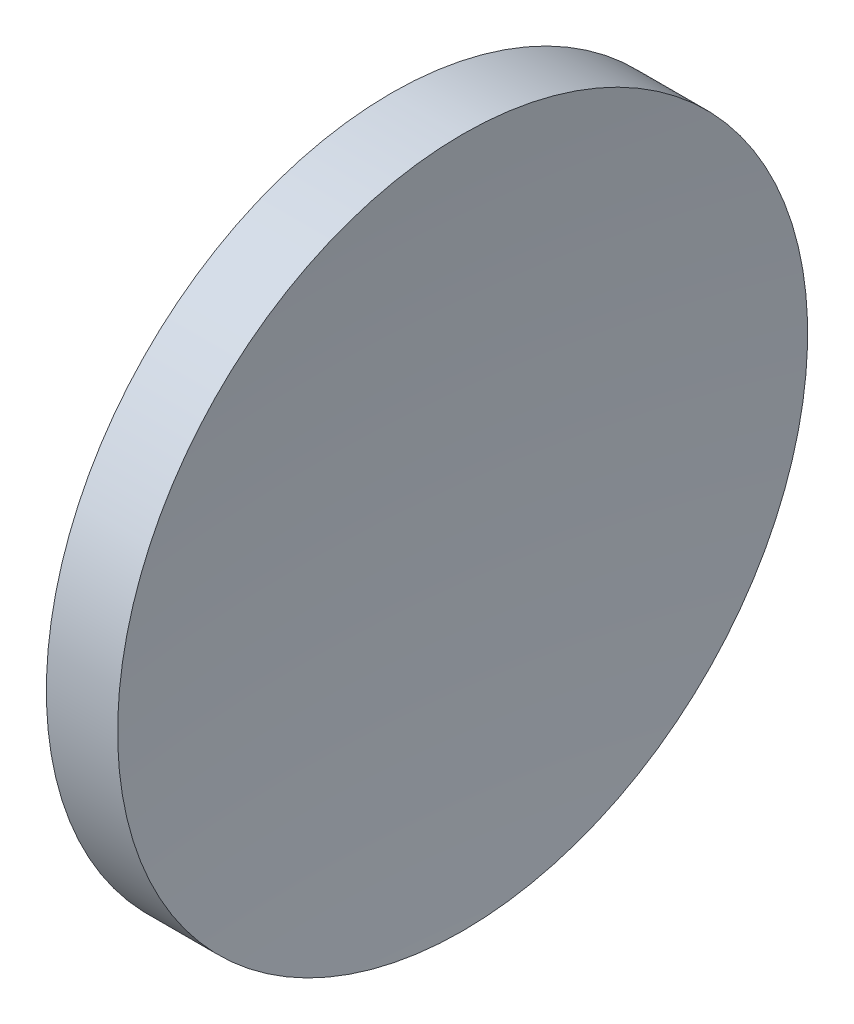
from build123d import *


with BuildPart() as part:
    # 草图1 → 旋转1 (revolve)
    with BuildSketch(Plane.XY):
        with BuildLine():
            Line((124.383152534, 77.716840471), (126.965011076, 77.716840471))
            ThreePointArc((126.965011076, 77.716840471), (126.475509176, 71.475358078), (126.312193698, 65.216840471))
            Line((126.312193698, 65.216840471), (122.612193698, 65.216840471))
            ThreePointArc((122.612193698, 65.216840471), (123.057133086, 71.529254732), (124.383152534, 77.716840471))
        make_face()
    revolve(axis=Axis((115.944491298, 65.216840471, 0), (1, 0, 0)))


solid = part.part
